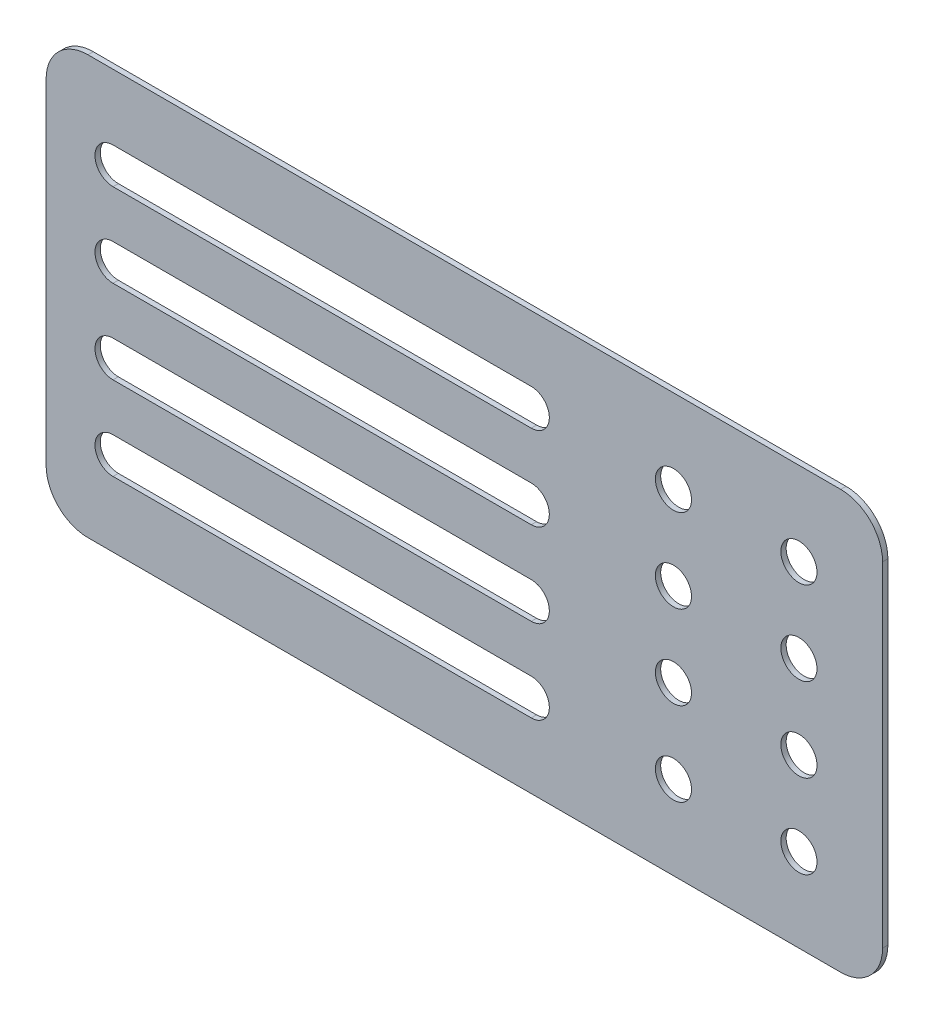
from build123d import *

# Parameters (mm, degrees)
SKETCH1_W           = 100
SKETCH1_H           = 50
SKETCH1_R           = 2.16
BOSS_EXTRUDE1_DEPTH = 0.635
FILLET1_R           = 5


with BuildPart() as part:
    # Sketch1 → Boss-Extrude1 (new body)
    with BuildSketch(Plane.XY):
        with Locations((50, -25)):
            Rectangle(SKETCH1_W, SKETCH1_H)
        with Locations((75, -10)):
            Circle(SKETCH1_R, mode=Mode.SUBTRACT)
        with Locations((90, -10)):
            Circle(SKETCH1_R, mode=Mode.SUBTRACT)
        with Locations((75, -20)):
            Circle(SKETCH1_R, mode=Mode.SUBTRACT)
        with Locations((90, -20)):
            Circle(SKETCH1_R, mode=Mode.SUBTRACT)
        with Locations((75, -30)):
            Circle(SKETCH1_R, mode=Mode.SUBTRACT)
        with Locations((90, -30)):
            Circle(SKETCH1_R, mode=Mode.SUBTRACT)
        with Locations((75, -40)):
            Circle(SKETCH1_R, mode=Mode.SUBTRACT)
        with Locations((90, -40)):
            Circle(SKETCH1_R, mode=Mode.SUBTRACT)
        with BuildLine():
            Line((8, -7.84), (58, -7.84))
            ThreePointArc((58, -7.84), (60.16, -10), (58, -12.16))
            Line((58, -12.16), (8, -12.16))
            ThreePointArc((8, -12.16), (5.84, -10), (8, -7.84))
        make_face(mode=Mode.SUBTRACT)
        with BuildLine():
            Line((8, -22.16), (58, -22.16))
            ThreePointArc((58, -22.16), (60.16, -20), (58, -17.84))
            Line((58, -17.84), (8, -17.84))
            ThreePointArc((8, -17.84), (5.84, -20), (8, -22.16))
        make_face(mode=Mode.SUBTRACT)
        with BuildLine():
            Line((8, -32.16), (58, -32.16))
            ThreePointArc((58, -32.16), (60.16, -30), (58, -27.84))
            Line((58, -27.84), (8, -27.84))
            ThreePointArc((8, -27.84), (5.84, -30), (8, -32.16))
        make_face(mode=Mode.SUBTRACT)
        with BuildLine():
            Line((8, -42.16), (58, -42.16))
            ThreePointArc((58, -42.16), (60.16, -40), (58, -37.84))
            Line((58, -37.84), (8, -37.84))
            ThreePointArc((8, -37.84), (5.84, -40), (8, -42.16))
        make_face(mode=Mode.SUBTRACT)
    extrude(amount=BOSS_EXTRUDE1_DEPTH)

    # Fillet1
    fillet1_edges = [part.edges().sort_by_distance(p)[0] for p in [
        (100, 0, 0.3175),
        (100, -50, 0.3175),
        (0, -50, 0.3175),
        (0, 0, 0.3175),
    ]]
    fillet(fillet1_edges, radius=FILLET1_R)


solid = part.part
